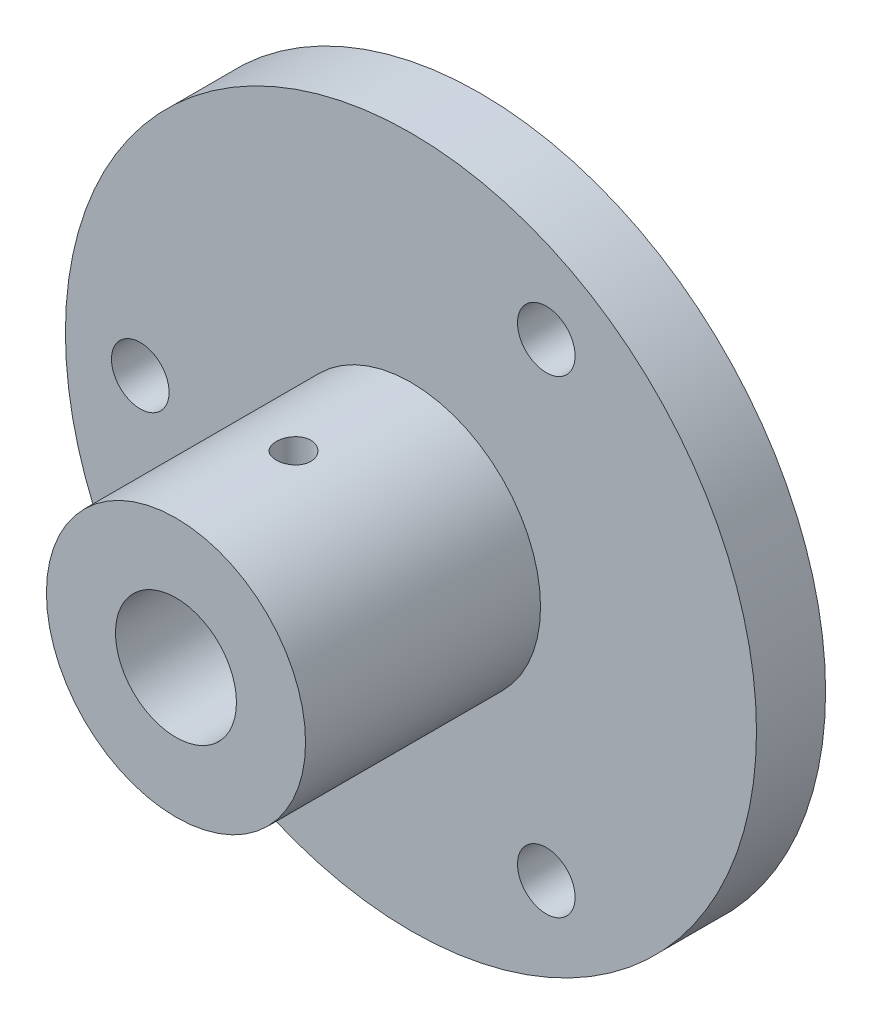
from build123d import *

# Parameters (mm, degrees)
SKETCH_1_R               = 30
SKETCH_1_R_2             = 2.5
SKETCH_1_R_3             = 5.25
EXTRUDE_1_DEPTH          = 6
SKETCH_3_R               = 11.25
SKETCH_3_R_2             = 5.25
EXTRUDE_2_DEPTH          = 20.4
SKETCH_4_R               = 1.5
CUT_EXTRUDE_1_DEPTH      = 31
CUT_EXTRUDE_1_DEPTH_BACK = 31


with BuildPart() as part:
    # ｽｹｯﾁ1 → ﾎﾞｽ - 押し出し1 (new body)
    with BuildSketch(Plane.XY):
        Circle(SKETCH_1_R)
        with Locations((-23.5, 0)):
            Circle(SKETCH_1_R_2, mode=Mode.SUBTRACT)
        with Locations((11.75, -20.351596989)):
            Circle(SKETCH_1_R_2, mode=Mode.SUBTRACT)
        with Locations((11.75, 20.351596989)):
            Circle(SKETCH_1_R_2, mode=Mode.SUBTRACT)
        Circle(SKETCH_1_R_3, mode=Mode.SUBTRACT)
    extrude(amount=EXTRUDE_1_DEPTH)

    # ｽｹｯﾁ3 → ﾎﾞｽ - 押し出し2 (add)
    with BuildSketch(Plane.XY.offset(6)):
        Circle(SKETCH_3_R)
        Circle(SKETCH_3_R_2, mode=Mode.SUBTRACT)
    extrude(amount=EXTRUDE_2_DEPTH)

    # ｽｹｯﾁ4 → ｶｯﾄ - 押し出し1 (cut, two sides)
    with BuildSketch(Plane(origin=(0, 0, 0), x_dir=(1, 0, 0), z_dir=(0, 1, 0))) as cut_extrude_1_sk:
        with Locations((0, -16.2)):
            Circle(SKETCH_4_R)
    extrude(amount=CUT_EXTRUDE_1_DEPTH, mode=Mode.SUBTRACT)
    extrude(cut_extrude_1_sk.sketch, amount=-CUT_EXTRUDE_1_DEPTH_BACK, mode=Mode.SUBTRACT)


solid = part.part
